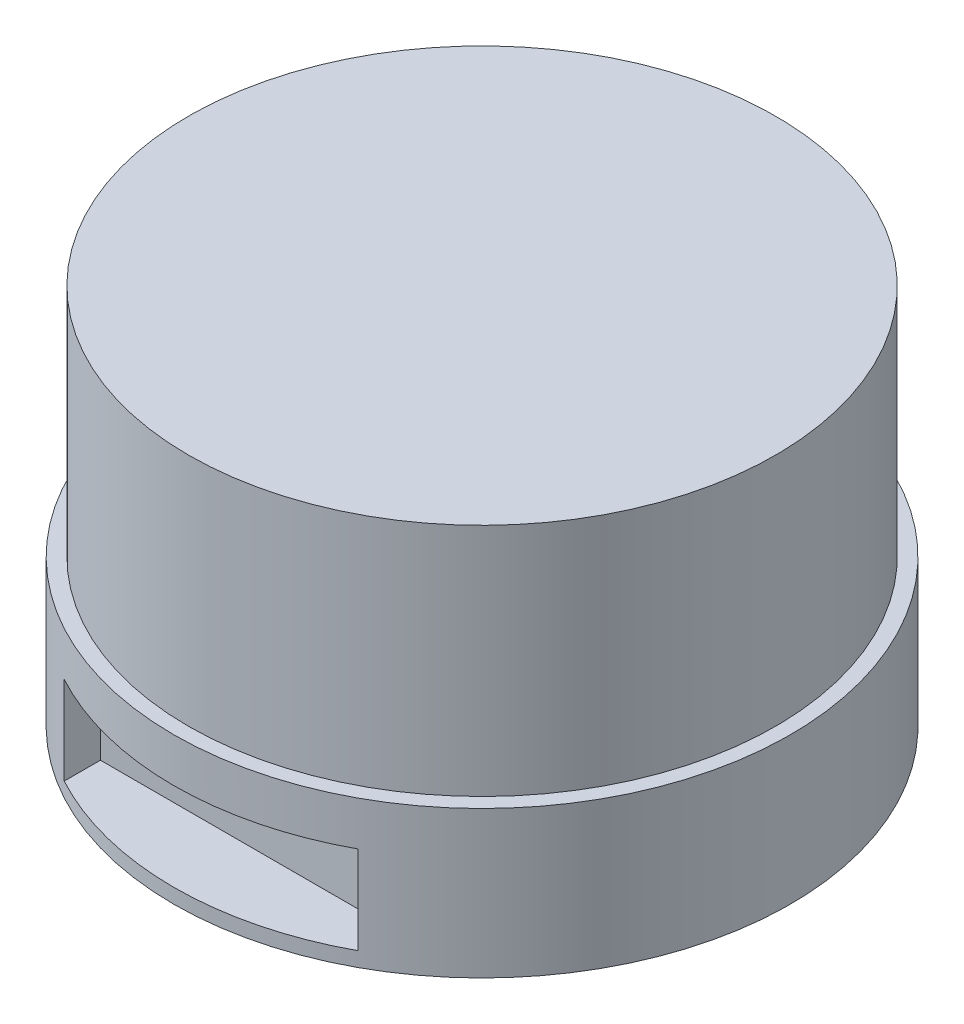
from build123d import *

# Parameters (mm, degrees)
SKETCH_1_R          = 21
EXTRUDE_1_DEPTH     = 10
SKETCH_4_R          = 20
EXTRUDE_3_DEPTH     = 16
SKETCH_6_R          = 1.5
CUT_EXTRUDE_1_DEPTH = 4
SKETCH_7_R          = 10
SKETCH_7_R_2        = 9
EXTRUDE_4_DEPTH     = 1.5
SKETCH_8_W          = 20
SKETCH_8_H          = 6
CUT_EXTRUDE_2_DEPTH = 5


with BuildPart() as part:
    # 草图1 → 凸台-拉伸1 (new body)
    with BuildSketch(Plane(origin=(0, 0, 0), x_dir=(1, 0, 0), z_dir=(0, 1, 0))):
        Circle(SKETCH_1_R)
    extrude(amount=EXTRUDE_1_DEPTH)

    # 草图4 → 凸台-拉伸3 (add)
    with BuildSketch(Plane(origin=(0, 10, 0), x_dir=(1, 0, 0), z_dir=(0, 1, 0))):
        Circle(SKETCH_4_R)
    extrude(amount=EXTRUDE_3_DEPTH)

    # 草图6 → 切除-拉伸1 (cut)
    with BuildSketch(Plane.XZ):
        with Locations((12.727922061, 12.727922061)):
            Circle(SKETCH_6_R)
        with Locations((12.727922061, -12.727922061)):
            Circle(SKETCH_6_R)
        with Locations((-12.727922061, -12.727922061)):
            Circle(SKETCH_6_R)
        with Locations((-12.727922061, 12.727922061)):
            Circle(SKETCH_6_R)
    extrude(amount=-CUT_EXTRUDE_1_DEPTH, mode=Mode.SUBTRACT)

    # 草图7 → 凸台-拉伸4 (add)
    with BuildSketch(Plane.XZ):
        Circle(SKETCH_7_R)
        Circle(SKETCH_7_R_2, mode=Mode.SUBTRACT)
    extrude(amount=EXTRUDE_4_DEPTH)

    # 草图8 → 切除-拉伸2 (cut)
    with BuildSketch(Plane.XY.offset(21)):
        with Locations((0, 4)):
            Rectangle(SKETCH_8_W, SKETCH_8_H)
    extrude(amount=-CUT_EXTRUDE_2_DEPTH, mode=Mode.SUBTRACT)


solid = part.part
